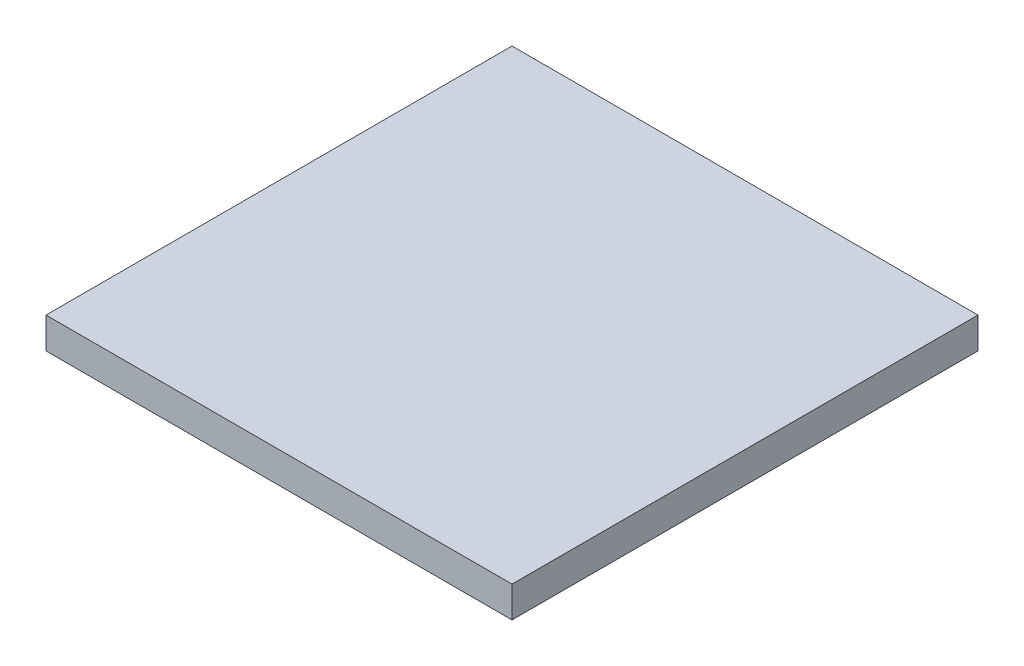
from build123d import *

# Parameters (mm, degrees)
BASES_W    = 15
BASES_H    = 15
BASE_DEPTH = 1


with BuildPart() as part:
    # BaseS → Base (new body)
    with BuildSketch(Plane(origin=(0, 0, 0), x_dir=(1, 0, 0), z_dir=(0, 1, 0))):
        Rectangle(BASES_W, BASES_H)
    extrude(amount=BASE_DEPTH)


solid = part.part
